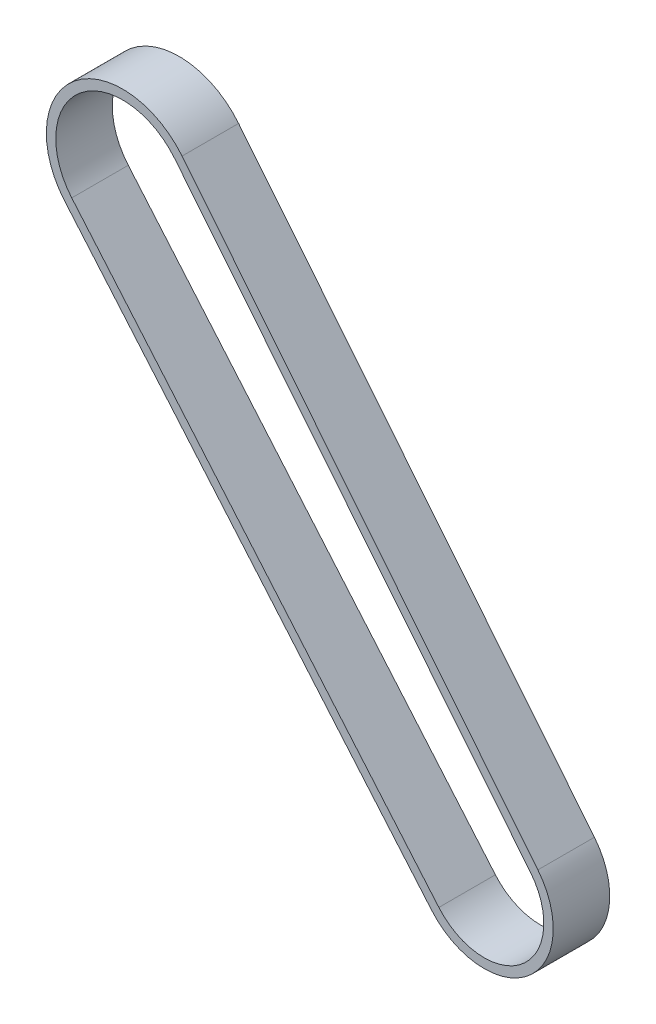
from build123d import *

# Parameters (mm, degrees)
EXTRUDE_1_DEPTH = 6


with BuildPart() as part:
    # 草图2 → 拉伸-薄壁1 (new body)
    with BuildSketch(Plane.XY):
        with BuildLine():
            Line((32.798331051, -50.992317564), (-6.168725965, -5.255679902))
            ThreePointArc((-6.168725965, -5.255679902), (-5.175264059, 6.236344695), (6.302915185, 5.093979982))
            Line((6.302915185, 5.093979982), (44.071084265, -41.637561416))
            ThreePointArc((44.071084265, -41.637561416), (43.051834725, -51.878711881), (32.798331051, -50.992317564))
        make_face()
        with BuildLine():
            Line((33.559523198, -50.343791146), (-5.407533817, -4.607153484))
            ThreePointArc((-5.407533817, -4.607153484), (-4.536660483, 5.466808814), (5.525164914, 4.465406585))
            Line((5.525164914, 4.465406585), (43.293333994, -42.266134813))
            ThreePointArc((43.293333994, -42.266134813), (42.413231149, -51.109176), (33.559523198, -50.343791146))
        make_face(mode=Mode.SUBTRACT)
    extrude(amount=EXTRUDE_1_DEPTH)


solid = part.part
